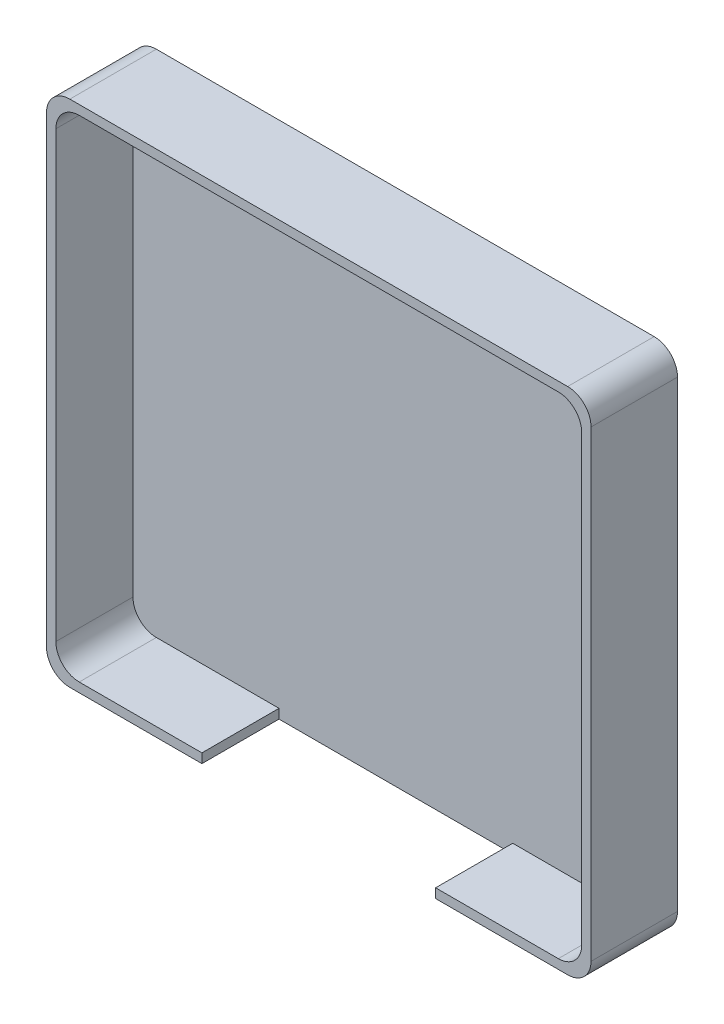
from build123d import *

# Parameters (mm, degrees)
SKETCH_1_W          = 46.6
SKETCH_1_H          = 43.6
EXTRUDE_1_DEPTH     = 7.4
SKETCH_2_W          = 45
SKETCH_2_H          = 42
CUT_EXTRUDE_1_DEPTH = 6.6
CUT_EXTRUDE_3_REACH = 45.6
SKETCH_3_W          = 20
SKETCH_3_H          = 6.6
FILLET_1_R          = 2


with BuildPart() as part:
    # ｽｹｯﾁ1 → ﾎﾞｽ - 押し出し1 (new body)
    with BuildSketch(Plane.XY):
        Rectangle(SKETCH_1_W, SKETCH_1_H)
    extrude(amount=EXTRUDE_1_DEPTH)

    # ｽｹｯﾁ2 → ｶｯﾄ - 押し出し1 (cut)
    with BuildSketch(Plane.XY.offset(7.4)):
        Rectangle(SKETCH_2_W, SKETCH_2_H)
    extrude(amount=-CUT_EXTRUDE_1_DEPTH, mode=Mode.SUBTRACT)

    # ｽｹｯﾁ3 → ｶｯﾄ - 押し出し3 (cut, up to next)
    with BuildSketch(Plane(origin=(0, -21.8, 0), x_dir=(-1, 0, 0), z_dir=(0, -1, 0)), mode=Mode.PRIVATE) as cut_extrude_3_sk1:
        with Locations((0, -4.1)):
            Rectangle(SKETCH_3_W, SKETCH_3_H)
    cut_extrude_3_tool1 = extrude(cut_extrude_3_sk1.sketch, amount=-CUT_EXTRUDE_3_REACH, mode=Mode.PRIVATE) & part.part
    add(cut_extrude_3_tool1.solids().sort_by_distance((0, -21.8, 4.1))[0], mode=Mode.SUBTRACT)

    # ﾌｨﾚｯﾄ1
    fillet_1_edges = [part.edges().sort_by_distance(p)[0] for p in [
        (-22.5, -21, 4.1),
        (-22.5, 21, 4.1),
        (22.5, 21, 4.1),
        (22.5, -21, 4.1),
        (23.3, -21.8, 3.7),
        (-23.3, -21.8, 3.7),
        (-23.3, 21.8, 3.7),
        (23.3, 21.8, 3.7),
    ]]
    fillet(fillet_1_edges, radius=FILLET_1_R)


solid = part.part
